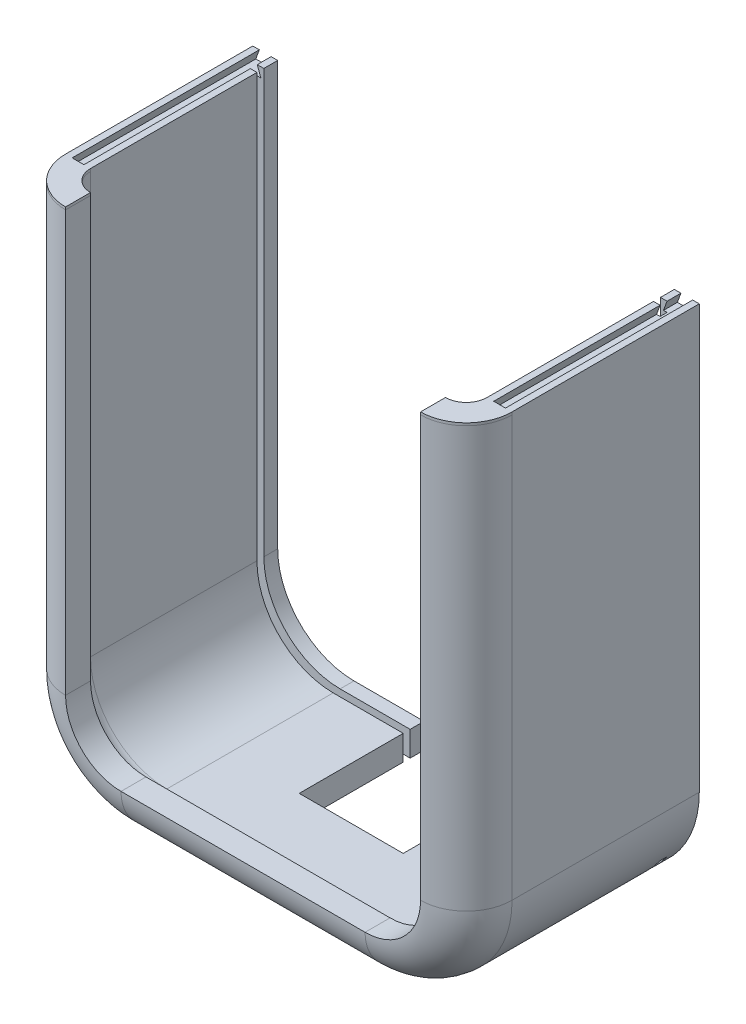
from build123d import *

# Parameters (mm, degrees)
EXTRUDE_1_DEPTH     = 27
CUT_EXTRUDE_START   = -1
CUT_EXTRUDE_1_DEPTH = 1
SKETCH_4_W          = 15
SKETCH_4_H          = 3.6
CUT_EXTRUDE_2_DEPTH = 55.688566867
SKETCH_4_2_W        = 15
SKETCH_4_2_H        = 3.6
CUT_EXTRUDE_3_DEPTH = 13


with BuildPart() as part:
    # 草圖1 → 填料-伸長1 (new body)
    with BuildSketch(Plane.XY):
        with BuildLine():
            Line((-17.6, -33.659429503), (17.6, -33.659429503))
            ThreePointArc((17.6, -33.659429503), (25.378174593, -30.437604096), (28.6, -22.659429503))
            Line((28.6, -22.659429503), (28.6, 38.340570497))
            Line((28.6, 38.340570497), (29.55, 38.340570497))
            Line((29.55, 38.340570497), (29.040441672, 36.940570497))
            Line((29.040441672, 36.940570497), (31.759558328, 36.940570497))
            Line((31.759558328, 36.940570497), (31.25, 38.340570497))
            Line((31.25, 38.340570497), (32.2, 38.340570497))
            Line((32.2, 38.340570497), (32.2, -22.659429503))
            ThreePointArc((32.2, -22.659429503), (27.923759005, -32.983188509), (17.6, -37.259429503))
            Line((17.6, -37.259429503), (-17.6, -37.259429503))
            ThreePointArc((-17.6, -37.259429503), (-27.923759005, -32.983188509), (-32.2, -22.659429503))
            Line((-32.2, -22.659429503), (-32.2, 38.340570497))
            Line((-32.2, 38.340570497), (-31.25, 38.340570497))
            Line((-31.25, 38.340570497), (-31.759558328, 36.940570497))
            Line((-31.759558328, 36.940570497), (-29.040441672, 36.940570497))
            Line((-29.040441672, 36.940570497), (-29.55, 38.340570497))
            Line((-29.55, 38.340570497), (-28.6, 38.340570497))
            Line((-28.6, 38.340570497), (-28.6, -22.659429503))
            ThreePointArc((-28.6, -22.659429503), (-25.378174593, -30.437604096), (-17.6, -33.659429503))
        make_face()
    extrude(amount=EXTRUDE_1_DEPTH)

    # 草圖3 → 除料-伸長1 (cut)
    with BuildSketch(Plane.XY.offset(3).offset(CUT_EXTRUDE_START)):
        with BuildLine():
            Line((-28.6, 38.340570497), (-28.6, -22.659429503))
            ThreePointArc((-28.6, -22.659429503), (-25.378174593, -30.437604096), (-17.6, -33.659429503))
            Line((-17.6, -33.659429503), (17.6, -33.659429503))
            ThreePointArc((17.6, -33.659429503), (25.378174593, -30.437604096), (28.6, -22.659429503))
            Line((28.6, -22.659429503), (28.6, 38.340570497))
            Line((28.6, 38.340570497), (29.56, 38.340570497))
            Line((29.56, 38.340570497), (29.56, -22.659429503))
            Line((29.56, -22.659429503), (29.56, -37.259429503))
            Line((29.56, -37.259429503), (-29.56, -37.259429503))
            Line((-29.56, -37.259429503), (-29.56, -22.659429503))
            Line((-29.56, -22.659429503), (-29.56, 38.340570497))
            Line((-29.56, 38.340570497), (-28.6, 38.340570497))
        make_face()
    extrude(amount=CUT_EXTRUDE_1_DEPTH, mode=Mode.SUBTRACT)

    # 草圖4 → 除料-伸長2 (cut, through all)
    with BuildSketch(Plane.XY.offset(5)):
        with Locations((0, -35.459429503)):
            Rectangle(SKETCH_4_W, SKETCH_4_H)
    extrude(amount=-CUT_EXTRUDE_2_DEPTH, mode=Mode.SUBTRACT)

    # 掃出4: sweep along a path in 草圖6
    with BuildLine(Plane.XY.offset(27)) as sweep_4_path:
        Line((-30.4, 38.340570497), (-30.4, 37.968733181))
        Line((-30.4, 37.968733181), (-30.4, -22.659429503))
        ThreePointArc((-30.4, -22.659429503), (-26.650966799, -31.710396303), (-17.6, -35.459429503))
        Line((-17.6, -35.459429503), (17.6, -35.459429503))
        ThreePointArc((17.6, -35.459429503), (26.650966799, -31.710396303), (30.4, -22.659429503))
        Line((30.4, -22.659429503), (30.4, 37.968733181))
        Line((30.4, 37.968733181), (30.4, 38.340570497))
    # 草圖7 → 掃出4 (sweep)
    with BuildSketch(Plane(origin=(0, 36.940570497, 0), x_dir=(1, 0, 0), z_dir=(0, 1, 0))):
        with BuildLine():
            Line((-32.2, -27), (-28.6, -27))
            ThreePointArc((-28.6, -27), (-27.721320344, -29.121320344), (-25.6, -30))
            Line((-25.6, -30), (-25.6, -33.6))
            ThreePointArc((-25.6, -33.6), (-30.266904756, -31.666904756), (-32.2, -27))
        make_face()
    sweep(path=sweep_4_path.line)

    # 草圖4<2> → 除料-伸長3 (cut)
    with BuildSketch(Plane.XY.offset(5)):
        with Locations((0, -35.459429503)):
            Rectangle(SKETCH_4_2_W, SKETCH_4_2_H)
    extrude(amount=CUT_EXTRUDE_3_DEPTH, mode=Mode.SUBTRACT)


solid = part.part
